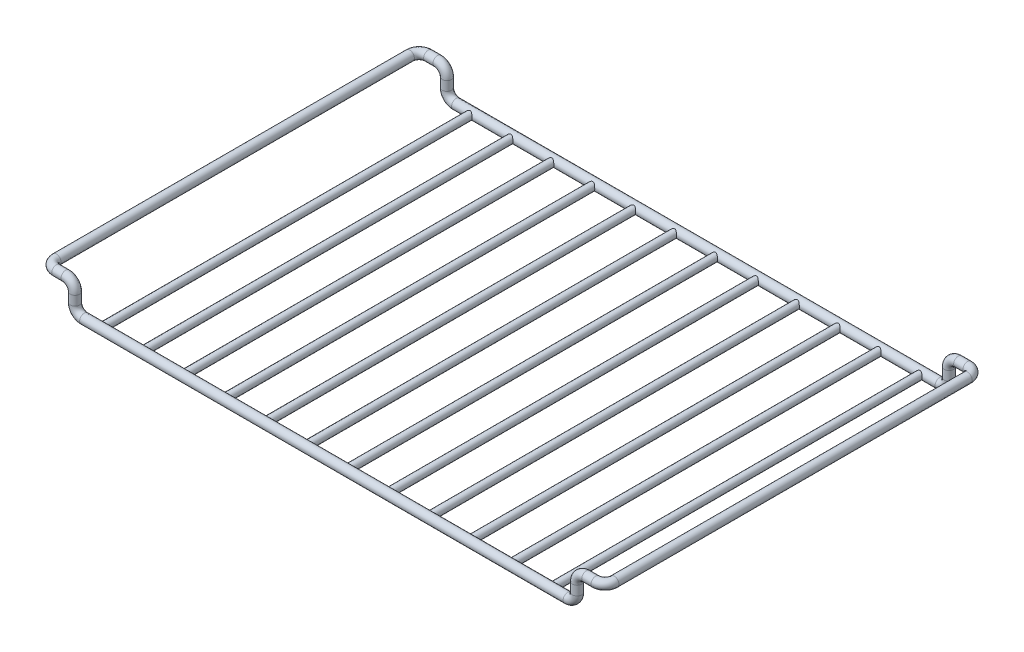
from build123d import *

# Parameters (mm, degrees)
CROQUIS1_R                  = 2.5
EXTRUIR1_REACH              = 256.104
EXTRUIR1_END_RADIUS         = 2.5
CROQUIS2_R                  = 2
MATRIZL1_COUNT              = 6
MATRIZL1_PITCH              = 22
SIMETR_A1_COPY_1_REACH      = 256.104
SIMETR_A1_COPY_1_END_RADIUS = 2.5
SIMETR_A1_COPY_1_SKETCH_R   = 2
SIMETR_A1_COPY_2_REACH      = 256.104
SIMETR_A1_COPY_2_END_RADIUS = 2.5
SIMETR_A1_COPY_2_SKETCH_R   = 2
SIMETR_A1_COPY_3_REACH      = 256.104
SIMETR_A1_COPY_3_END_RADIUS = 2.5
SIMETR_A1_COPY_3_SKETCH_R   = 2
SIMETR_A1_COPY_4_REACH      = 256.104
SIMETR_A1_COPY_4_END_RADIUS = 2.5
SIMETR_A1_COPY_4_SKETCH_R   = 2
SIMETR_A1_COPY_5_REACH      = 256.104
SIMETR_A1_COPY_5_END_RADIUS = 2.5
SIMETR_A1_COPY_5_SKETCH_R   = 2


with BuildPart() as part:
    # Barrer1: sweep along a curve in space
    with BuildLine() as barrer1_path:
        Line((0, 0, 0), (130, 0, 0))
        ThreePointArc((130, 0, 0), (133.535533906, 1.464466094, 0), (135, 5, 0))
        Line((135, 5, 0), (135, 10, 0))
        ThreePointArc((135, 10, 0), (136.464466094, 13.535533906, 0), (140, 15, 0))
        Line((140, 15, 0), (145, 15, 0))
        ThreePointArc((145, 15, 0), (148.535533906, 15, -1.464466094), (150, 15, -5))
        Line((150, 15, -5), (150, 15, -195))
        ThreePointArc((150, 15, -195), (148.535533906, 15, -198.535533906), (145, 15, -200))
        Line((145, 15, -200), (140, 15, -200))
        ThreePointArc((140, 15, -200), (136.464466094, 13.535533906, -200), (135, 10, -200))
        Line((135, 10, -200), (135, 5, -200))
        ThreePointArc((135, 5, -200), (133.535533906, 1.464466094, -200), (130, 0, -200))
        Line((130, 0, -200), (0, 0, -200))
    # Croquis1 → Barrer1 (sweep)
    with BuildSketch(Plane(origin=(0, 0, 0), x_dir=(0, 0, -1), z_dir=(1, 0, 0))):
        Circle(CROQUIS1_R)
    barrer1 = sweep(path=barrer1_path.line)

    # Extruir1: up to this cylinder (the profile starts outside it)
    extruir1_end = Plane(origin=(11, 0, -200), z_dir=(-1, 0, 0)) * Cylinder(EXTRUIR1_END_RADIUS, 518.208, mode=Mode.PRIVATE)
    # Croquis2 → Extruir1 (add, up to the surface)
    with BuildSketch(Plane.XY, mode=Mode.PRIVATE) as extruir1_sk1:
        with Locations((11, 0)):
            Circle(CROQUIS2_R)
    extruir1_tool1 = extrude(extruir1_sk1.sketch, amount=-EXTRUIR1_REACH, mode=Mode.PRIVATE) - extruir1_end
    extruir1 = extruir1_tool1.solids().sort_by_distance((11, 0, 0))[0]
    add(extruir1)

    # MatrizL1: Extruir1 ×6
    with Locations(*[(i * MATRIZL1_PITCH, 0, 0) for i in range(1, MATRIZL1_COUNT)]):
        add(extruir1)

    # Simetría1: Barrer1, Extruir1 across plane
    add(barrer1.mirror(Plane(origin=(0, 0, 0), x_dir=(0, 0, 1), z_dir=(1, 0, 0))))
    add(extruir1.mirror(Plane(origin=(0, 0, 0), x_dir=(0, 0, 1), z_dir=(1, 0, 0))))

    # Simetría1 copy 1: up to this cylinder (the profile starts outside it)
    simetr_a1_copy_1_end = Plane(origin=(11, 0, -200), z_dir=(-1, 0, 0)) * Cylinder(SIMETR_A1_COPY_1_END_RADIUS, 518.208, mode=Mode.PRIVATE)
    # Simetría1 copy 1 sketch → Simetría1 copy 1 (add, up to the surface)
    with BuildSketch(Plane(origin=(-22, 0, 0), x_dir=(-1, 0, 0), z_dir=(0, 0, 1)), mode=Mode.PRIVATE) as simetr_a1_copy_1_sk1:
        with Locations((11, 0)):
            Circle(SIMETR_A1_COPY_1_SKETCH_R)
    simetr_a1_copy_1_tool1 = extrude(simetr_a1_copy_1_sk1.sketch, amount=-SIMETR_A1_COPY_1_REACH, mode=Mode.PRIVATE) - simetr_a1_copy_1_end
    add(simetr_a1_copy_1_tool1.solids().sort_by_distance((11, 0, 0))[0])

    # Simetría1 copy 2: up to this cylinder (the profile starts outside it)
    simetr_a1_copy_2_end = Plane(origin=(11, 0, -200), z_dir=(-1, 0, 0)) * Cylinder(SIMETR_A1_COPY_2_END_RADIUS, 518.208, mode=Mode.PRIVATE)
    # Simetría1 copy 2 sketch → Simetría1 copy 2 (add, up to the surface)
    with BuildSketch(Plane(origin=(-44, 0, 0), x_dir=(-1, 0, 0), z_dir=(0, 0, 1)), mode=Mode.PRIVATE) as simetr_a1_copy_2_sk1:
        with Locations((11, 0)):
            Circle(SIMETR_A1_COPY_2_SKETCH_R)
    simetr_a1_copy_2_tool1 = extrude(simetr_a1_copy_2_sk1.sketch, amount=-SIMETR_A1_COPY_2_REACH, mode=Mode.PRIVATE) - simetr_a1_copy_2_end
    add(simetr_a1_copy_2_tool1.solids().sort_by_distance((11, 0, 0))[0])

    # Simetría1 copy 3: up to this cylinder (the profile starts outside it)
    simetr_a1_copy_3_end = Plane(origin=(11, 0, -200), z_dir=(-1, 0, 0)) * Cylinder(SIMETR_A1_COPY_3_END_RADIUS, 518.208, mode=Mode.PRIVATE)
    # Simetría1 copy 3 sketch → Simetría1 copy 3 (add, up to the surface)
    with BuildSketch(Plane(origin=(-66, 0, 0), x_dir=(-1, 0, 0), z_dir=(0, 0, 1)), mode=Mode.PRIVATE) as simetr_a1_copy_3_sk1:
        with Locations((11, 0)):
            Circle(SIMETR_A1_COPY_3_SKETCH_R)
    simetr_a1_copy_3_tool1 = extrude(simetr_a1_copy_3_sk1.sketch, amount=-SIMETR_A1_COPY_3_REACH, mode=Mode.PRIVATE) - simetr_a1_copy_3_end
    add(simetr_a1_copy_3_tool1.solids().sort_by_distance((11, 0, 0))[0])

    # Simetría1 copy 4: up to this cylinder (the profile starts outside it)
    simetr_a1_copy_4_end = Plane(origin=(11, 0, -200), z_dir=(-1, 0, 0)) * Cylinder(SIMETR_A1_COPY_4_END_RADIUS, 518.208, mode=Mode.PRIVATE)
    # Simetría1 copy 4 sketch → Simetría1 copy 4 (add, up to the surface)
    with BuildSketch(Plane(origin=(-88, 0, 0), x_dir=(-1, 0, 0), z_dir=(0, 0, 1)), mode=Mode.PRIVATE) as simetr_a1_copy_4_sk1:
        with Locations((11, 0)):
            Circle(SIMETR_A1_COPY_4_SKETCH_R)
    simetr_a1_copy_4_tool1 = extrude(simetr_a1_copy_4_sk1.sketch, amount=-SIMETR_A1_COPY_4_REACH, mode=Mode.PRIVATE) - simetr_a1_copy_4_end
    add(simetr_a1_copy_4_tool1.solids().sort_by_distance((11, 0, 0))[0])

    # Simetría1 copy 5: up to this cylinder (the profile starts outside it)
    simetr_a1_copy_5_end = Plane(origin=(11, 0, -200), z_dir=(-1, 0, 0)) * Cylinder(SIMETR_A1_COPY_5_END_RADIUS, 518.208, mode=Mode.PRIVATE)
    # Simetría1 copy 5 sketch → Simetría1 copy 5 (add, up to the surface)
    with BuildSketch(Plane(origin=(-110, 0, 0), x_dir=(-1, 0, 0), z_dir=(0, 0, 1)), mode=Mode.PRIVATE) as simetr_a1_copy_5_sk1:
        with Locations((11, 0)):
            Circle(SIMETR_A1_COPY_5_SKETCH_R)
    simetr_a1_copy_5_tool1 = extrude(simetr_a1_copy_5_sk1.sketch, amount=-SIMETR_A1_COPY_5_REACH, mode=Mode.PRIVATE) - simetr_a1_copy_5_end
    add(simetr_a1_copy_5_tool1.solids().sort_by_distance((11, 0, 0))[0])


solid = part.part
